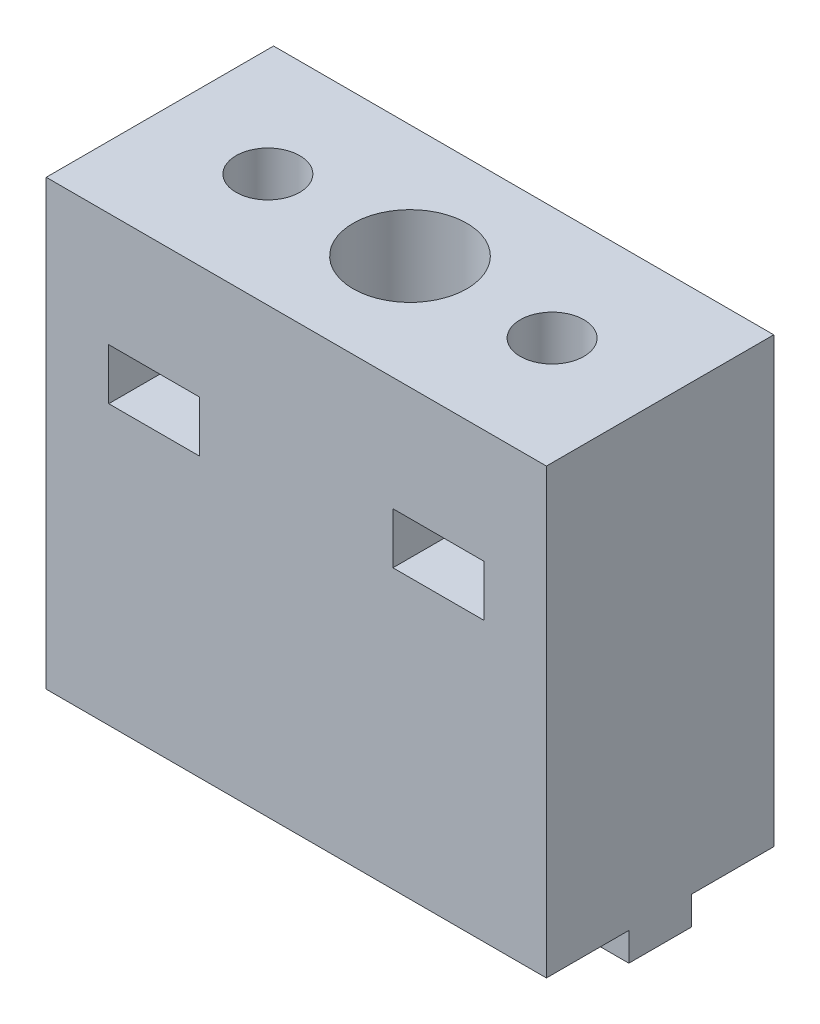
from build123d import *

# Parameters (mm, degrees)
SKETCH1_W           = 44
SKETCH1_H           = 20
BOSS_EXTRUDE1_DEPTH = 39
SKETCH3_W           = 44
SKETCH3_H           = 5.5
BOSS_EXTRUDE5_DEPTH = 2.5
SKETCH2_R           = 2.8
CUT_EXTRUDE1_DEPTH  = 42.5
SKETCH4_R           = 5
CUT_EXTRUDE2_DEPTH  = 34
SKETCH5_W           = 8
SKETCH5_H           = 4.5
CUT_EXTRUDE3_DEPTH  = 21
SKETCH6_W           = 10
SKETCH6_H           = 5.5
CUT_EXTRUDE4_DEPTH  = 2.5


with BuildPart() as part:
    # Sketch1 → Boss-Extrude1 (new body)
    with BuildSketch(Plane(origin=(0, 0, 0), x_dir=(1, 0, 0), z_dir=(0, 1, 0))):
        with Locations((21.30324178, 10)):
            Rectangle(SKETCH1_W, SKETCH1_H)
    extrude(amount=BOSS_EXTRUDE1_DEPTH)

    # Sketch3 → Boss-Extrude5 (add)
    with BuildSketch(Plane.XZ):
        with Locations((21.30324178, -10)):
            Rectangle(SKETCH3_W, SKETCH3_H)
    extrude(amount=BOSS_EXTRUDE5_DEPTH)

    # Sketch2 → Cut-Extrude1 (cut, through all)
    with BuildSketch(Plane(origin=(0, 39, 0), x_dir=(1, 0, 0), z_dir=(0, 1, 0))):
        with Locations((8.80324178, 10)):
            Circle(SKETCH2_R)
        with Locations((33.80324178, 10)):
            Circle(SKETCH2_R)
        with Locations((21.30324178, 10)):
            Circle(SKETCH2_R)
    extrude(amount=-CUT_EXTRUDE1_DEPTH, mode=Mode.SUBTRACT)

    # Sketch4 → Cut-Extrude2 (cut)
    with BuildSketch(Plane(origin=(0, 39, 0), x_dir=(1, 0, 0), z_dir=(0, 1, 0))):
        with Locations((21.30324178, 10)):
            Circle(SKETCH4_R)
    extrude(amount=-CUT_EXTRUDE2_DEPTH, mode=Mode.SUBTRACT)

    # Sketch5 → Cut-Extrude3 (cut, through all)
    with BuildSketch(Plane(origin=(0, 0, -20), x_dir=(-1, 0, 0), z_dir=(0, 0, -1))):
        with Locations((-33.80324178, 26.75)):
            Rectangle(SKETCH5_W, SKETCH5_H)
        with Locations((-8.80324178, 26.75)):
            Rectangle(SKETCH5_W, SKETCH5_H)
    extrude(amount=-CUT_EXTRUDE3_DEPTH, mode=Mode.SUBTRACT)

    # Sketch6 → Cut-Extrude4 (cut)
    with BuildSketch(Plane.XZ.offset(2.5)):
        with Locations((21.30324178, -10)):
            Rectangle(SKETCH6_W, SKETCH6_H)
    extrude(amount=-CUT_EXTRUDE4_DEPTH, mode=Mode.SUBTRACT)


solid = part.part
